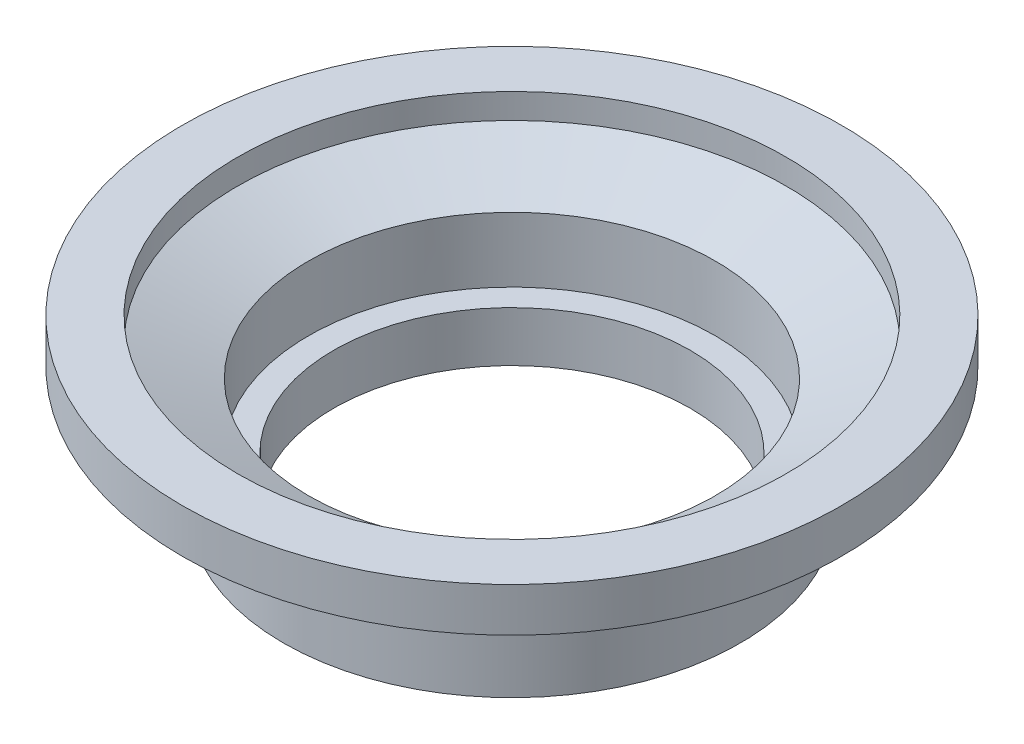
from build123d import *

# Parameters (mm, degrees)
SKETCH3_R      = 4.6228
SKETCH3_R_2    = 4.1148
EXTRUDE2_DEPTH = 0.508
SKETCH6_R      = 4.1148
EXTRUDE5_DEPTH = 1.016
SKETCH10_R     = 3.6068
EXTRUDE7_DEPTH = 4.429


with BuildPart() as part:
    # Sketch1 → Revolve1 (revolve)
    with BuildSketch(Plane.XY, mode=Mode.PRIVATE) as revolve1_sk:
        Polygon((4.6228, 0), (4.6228, 2.303790062), (6.6675, 3.048), (6.6675, 3.937), (5.5499, 3.937), (5.5499, 3.429), (4.1148, 2.834562117), (4.1148, 0), align=None)
    revolve(revolve1_sk.sketch.rotate(Axis((0, 0, 0), (0, -1, 0)), 90), axis=Axis((0, 0, 0), (0, -1, 0)))  # turned: the seam where the file's is

    # Sketch3 → Extrude2 (cut)
    with BuildSketch(Plane.XZ):
        with Locations(Location((0, 0, 0), (0, 0, 90))):  # turned: the seam where the file's is
            Circle(SKETCH3_R)
        with Locations(Location((0, 0, 0), (0, 0, 90))):  # turned: the seam where the file's is
            Circle(SKETCH3_R_2, mode=Mode.SUBTRACT)
    extrude(amount=-EXTRUDE2_DEPTH, mode=Mode.SUBTRACT)

    # Sketch6 → Extrude5 (add)
    with BuildSketch(Plane.XZ.offset(-0.508)):
        with Locations(Location((0, 0, 0), (0, 0, 90))):  # turned: the seam where the file's is
            Circle(SKETCH6_R)
    extrude(amount=-EXTRUDE5_DEPTH)

    # Sketch10 → Extrude7 (cut, through all)
    with BuildSketch(Plane.XZ.offset(-0.508)):
        with Locations(Location((0, 0, 0), (0, 0, 270))):  # turned: the seam where the file's is
            Circle(SKETCH10_R)
    extrude(amount=-EXTRUDE7_DEPTH, mode=Mode.SUBTRACT)


solid = part.part
